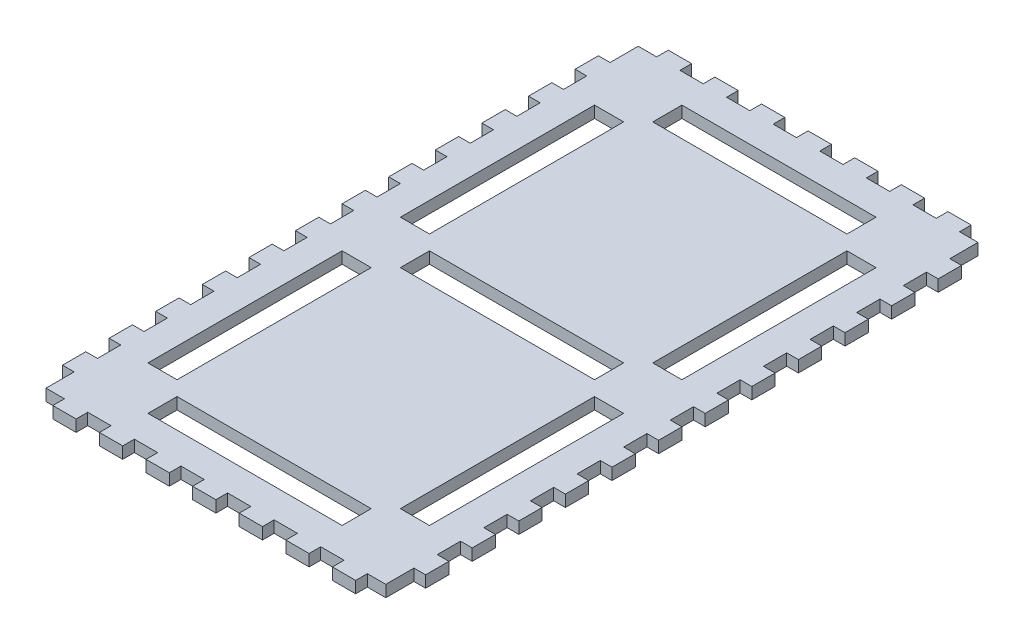
from build123d import *

# Parameters (mm, degrees)
SKETCH3_W           = 15
SKETCH3_H           = 100
SKETCH3_W_2         = 100
SKETCH3_H_2         = 15
BOSS_EXTRUDE4_DEPTH = 6


with BuildPart() as part:
    # Sketch3 → Boss-Extrude4 (new body)
    with BuildSketch(Plane(origin=(0, 0, 0), x_dir=(1, 0, 0), z_dir=(0, 1, 0))):
        Polygon((-87.5, -152.5), (-78, -152.5), (-78, -158.5), (-66, -158.5), (-66, -152.5), (-54, -152.5), (-54, -158.5), (-42, -158.5), (-42, -152.5), (-30, -152.5), (-30, -158.5), (-18, -158.5), (-18, -152.5), (-6, -152.5), (-6, -158.5), (6, -158.5), (6, -152.5), (18, -152.5), (18, -158.5), (30, -158.5), (30, -152.5), (42, -152.5), (42, -158.5), (54, -158.5), (54, -152.5), (66, -152.5), (66, -158.5), (78, -158.5), (78, -152.5), (87.5, -152.5), (87.5, -138), (93.5, -138), (93.5, -126), (87.5, -126), (87.5, -114), (93.5, -114), (93.5, -102), (87.5, -102), (87.5, -90), (93.5, -90), (93.5, -78), (87.5, -78), (87.5, -66), (93.5, -66), (93.5, -54), (87.5, -54), (87.5, -42), (93.5, -42), (93.5, -30), (87.5, -30), (87.5, -18), (93.5, -18), (93.5, -6), (87.5, -6), (87.5, 6), (93.5, 6), (93.5, 18), (87.5, 18), (87.5, 30), (93.5, 30), (93.5, 42), (87.5, 42), (87.5, 54), (93.5, 54), (93.5, 66), (87.5, 66), (87.5, 78), (93.5, 78), (93.5, 90), (87.5, 90), (87.5, 102), (93.5, 102), (93.5, 114), (87.5, 114), (87.5, 126), (93.5, 126), (93.5, 138), (87.5, 138), (87.5, 152.5), (78, 152.5), (78, 158.5), (66, 158.5), (66, 152.5), (54, 152.5), (54, 158.5), (42, 158.5), (42, 152.5), (30, 152.5), (30, 158.5), (18, 158.5), (18, 152.5), (6, 152.5), (6, 158.5), (-6, 158.5), (-6, 152.5), (-18, 152.5), (-18, 158.5), (-30, 158.5), (-30, 152.5), (-42, 152.5), (-42, 158.5), (-54, 158.5), (-54, 152.5), (-66, 152.5), (-66, 158.5), (-78, 158.5), (-78, 152.5), (-87.5, 152.5), (-87.5, 138), (-93.5, 138), (-93.5, 126), (-87.5, 126), (-87.5, 114), (-93.5, 114), (-93.5, 102), (-87.5, 102), (-87.5, 90), (-93.5, 90), (-93.5, 78), (-87.5, 78), (-87.5, 66), (-93.5, 66), (-93.5, 54), (-87.5, 54), (-87.5, 42), (-93.5, 42), (-93.5, 30), (-87.5, 30), (-87.5, 18), (-93.5, 18), (-93.5, 6), (-87.5, 6), (-87.5, -6), (-93.5, -6), (-93.5, -18), (-87.5, -18), (-87.5, -30), (-93.5, -30), (-93.5, -42), (-87.5, -42), (-87.5, -54), (-93.5, -54), (-93.5, -66), (-87.5, -66), (-87.5, -78), (-93.5, -78), (-93.5, -90), (-87.5, -90), (-87.5, -102), (-93.5, -102), (-93.5, -114), (-87.5, -114), (-87.5, -126), (-93.5, -126), (-93.5, -138), (-87.5, -138), align=None)
        with Locations((-65, -65)):
            Rectangle(SKETCH3_W, SKETCH3_H, mode=Mode.SUBTRACT)
        with Locations((0, -130)):
            Rectangle(SKETCH3_W_2, SKETCH3_H_2, mode=Mode.SUBTRACT)
        Rectangle(SKETCH3_W_2, SKETCH3_H_2, mode=Mode.SUBTRACT)
        with Locations((65, -65)):
            Rectangle(SKETCH3_W, SKETCH3_H, mode=Mode.SUBTRACT)
        with Locations((-65, 65)):
            Rectangle(SKETCH3_W, SKETCH3_H, mode=Mode.SUBTRACT)
        with Locations((65, 65)):
            Rectangle(SKETCH3_W, SKETCH3_H, mode=Mode.SUBTRACT)
        with Locations((0, 130)):
            Rectangle(SKETCH3_W_2, SKETCH3_H_2, mode=Mode.SUBTRACT)
    extrude(amount=BOSS_EXTRUDE4_DEPTH)


solid = part.part
